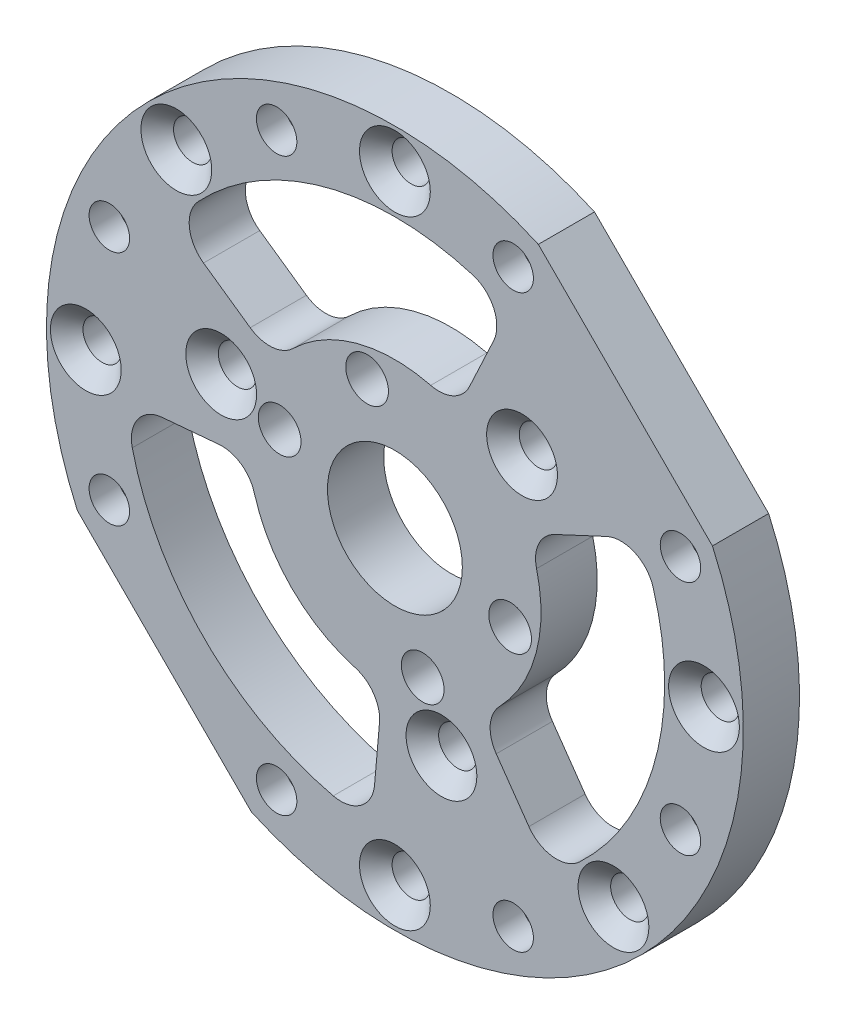
from build123d import *

# Parameters (mm, degrees)
SKETCH_1_R                          = 31
EXTRUDE_1_DEPTH                     = 5
SKETCH_2_R                          = 6
CUT_EXTRUDE_1_DEPTH                 = 6
HOLE_WIZARD_M3_1_D                  = 3.4
HOLE_WIZARD_M3_1_CSINK_D            = 6.3
HOLE_WIZARD_M3_1_CSINK_ANGLE        = 90
PATTERN_CIRCULAR_1_COUNT            = 8
CUT_EXTRUDE_2_DEPTH                 = 6
HOLE_WIZARD_M3_4_D                  = 3.4
HOLE_WIZARD_M3_4_CSINK_D            = 6.3
HOLE_WIZARD_M3_4_CSINK_ANGLE        = 90
PATTERN_CIRCULAR_3_COUNT            = 3
CUT_EXTRUDE_5_DEPTH                 = 2.5
HOLE_WIZARD_M3_2_D                  = 3.6
SKETCH_17_R                         = 0.3
CUT_EXTRUDE_6_DEPTH                 = 2.5
PATTERN_CIRCULAR_6_COUNT            = 6
PATTERN_CIRCULAR_7_COUNT            = 8
PATTERN_CIRCULAR_7_COPY_1_SKETCH_R  = 0.3
PATTERN_CIRCULAR_7_COPY_1_DEPTH     = 2.5
PATTERN_CIRCULAR_7_COPY_2_SKETCH_R  = 0.3
PATTERN_CIRCULAR_7_COPY_2_DEPTH     = 2.5
PATTERN_CIRCULAR_7_COPY_3_SKETCH_R  = 0.3
PATTERN_CIRCULAR_7_COPY_3_DEPTH     = 2.5
PATTERN_CIRCULAR_7_COPY_4_SKETCH_R  = 0.3
PATTERN_CIRCULAR_7_COPY_4_DEPTH     = 2.5
PATTERN_CIRCULAR_7_COPY_5_SKETCH_R  = 0.3
PATTERN_CIRCULAR_7_COPY_5_DEPTH     = 2.5
PATTERN_CIRCULAR_7_COPY_6_SKETCH_R  = 0.3
PATTERN_CIRCULAR_7_COPY_6_DEPTH     = 2.5
PATTERN_CIRCULAR_7_COPY_7_SKETCH_R  = 0.3
PATTERN_CIRCULAR_7_COPY_7_DEPTH     = 2.5
PATTERN_CIRCULAR_7_COPY_8_SKETCH_R  = 0.3
PATTERN_CIRCULAR_7_COPY_8_DEPTH     = 2.5
PATTERN_CIRCULAR_7_COPY_9_SKETCH_R  = 0.3
PATTERN_CIRCULAR_7_COPY_9_DEPTH     = 2.5
PATTERN_CIRCULAR_7_COPY_10_SKETCH_R = 0.3
PATTERN_CIRCULAR_7_COPY_10_DEPTH    = 2.5
PATTERN_CIRCULAR_7_COPY_11_SKETCH_R = 0.3
PATTERN_CIRCULAR_7_COPY_11_DEPTH    = 2.5
PATTERN_CIRCULAR_7_COPY_12_SKETCH_R = 0.3
PATTERN_CIRCULAR_7_COPY_12_DEPTH    = 2.5
PATTERN_CIRCULAR_7_COPY_13_SKETCH_R = 0.3
PATTERN_CIRCULAR_7_COPY_13_DEPTH    = 2.5
PATTERN_CIRCULAR_7_COPY_14_SKETCH_R = 0.3
PATTERN_CIRCULAR_7_COPY_14_DEPTH    = 2.5
PATTERN_CIRCULAR_7_COPY_15_SKETCH_R = 0.3
PATTERN_CIRCULAR_7_COPY_15_DEPTH    = 2.5
PATTERN_CIRCULAR_7_COPY_16_SKETCH_R = 0.3
PATTERN_CIRCULAR_7_COPY_16_DEPTH    = 2.5
PATTERN_CIRCULAR_7_COPY_17_SKETCH_R = 0.3
PATTERN_CIRCULAR_7_COPY_17_DEPTH    = 2.5
PATTERN_CIRCULAR_7_COPY_18_SKETCH_R = 0.3
PATTERN_CIRCULAR_7_COPY_18_DEPTH    = 2.5
PATTERN_CIRCULAR_7_COPY_19_SKETCH_R = 0.3
PATTERN_CIRCULAR_7_COPY_19_DEPTH    = 2.5
PATTERN_CIRCULAR_7_COPY_20_SKETCH_R = 0.3
PATTERN_CIRCULAR_7_COPY_20_DEPTH    = 2.5
PATTERN_CIRCULAR_7_COPY_21_SKETCH_R = 0.3
PATTERN_CIRCULAR_7_COPY_21_DEPTH    = 2.5
PATTERN_CIRCULAR_7_COPY_22_SKETCH_R = 0.3
PATTERN_CIRCULAR_7_COPY_22_DEPTH    = 2.5
PATTERN_CIRCULAR_7_COPY_23_SKETCH_R = 0.3
PATTERN_CIRCULAR_7_COPY_23_DEPTH    = 2.5
PATTERN_CIRCULAR_7_COPY_24_SKETCH_R = 0.3
PATTERN_CIRCULAR_7_COPY_24_DEPTH    = 2.5
PATTERN_CIRCULAR_7_COPY_25_SKETCH_R = 0.3
PATTERN_CIRCULAR_7_COPY_25_DEPTH    = 2.5
PATTERN_CIRCULAR_7_COPY_26_SKETCH_R = 0.3
PATTERN_CIRCULAR_7_COPY_26_DEPTH    = 2.5
PATTERN_CIRCULAR_7_COPY_27_SKETCH_R = 0.3
PATTERN_CIRCULAR_7_COPY_27_DEPTH    = 2.5
PATTERN_CIRCULAR_7_COPY_28_SKETCH_R = 0.3
PATTERN_CIRCULAR_7_COPY_28_DEPTH    = 2.5
PATTERN_CIRCULAR_7_COPY_29_SKETCH_R = 0.3
PATTERN_CIRCULAR_7_COPY_29_DEPTH    = 2.5
PATTERN_CIRCULAR_7_COPY_30_SKETCH_R = 0.3
PATTERN_CIRCULAR_7_COPY_30_DEPTH    = 2.5
PATTERN_CIRCULAR_7_COPY_31_SKETCH_R = 0.3
PATTERN_CIRCULAR_7_COPY_31_DEPTH    = 2.5
PATTERN_CIRCULAR_7_COPY_32_SKETCH_R = 0.3
PATTERN_CIRCULAR_7_COPY_32_DEPTH    = 2.5
PATTERN_CIRCULAR_7_COPY_33_SKETCH_R = 0.3
PATTERN_CIRCULAR_7_COPY_33_DEPTH    = 2.5
PATTERN_CIRCULAR_7_COPY_34_SKETCH_R = 0.3
PATTERN_CIRCULAR_7_COPY_34_DEPTH    = 2.5
PATTERN_CIRCULAR_7_COPY_35_SKETCH_R = 0.3
PATTERN_CIRCULAR_7_COPY_35_DEPTH    = 2.5
CUT_EXTRUDE_9_DEPTH                 = 6
FILLET_2_R                          = 3
PATTERN_CIRCULAR_10_COUNT           = 3
FILLET_2_OF_PATTERN_CIRCULAR_10_R   = 3
SKETCH_26_R                         = 1.9
CUT_EXTRUDE_10_DEPTH                = 3.5


with BuildPart() as part:
    # ｽｹｯﾁ1 → ﾎﾞｽ - 押し出し1 (new body)
    with BuildSketch(Plane.XY):
        Circle(SKETCH_1_R)
    extrude(amount=EXTRUDE_1_DEPTH)

    # ｽｹｯﾁ2 → ｶｯﾄ - 押し出し1 (cut, through all)
    with BuildSketch(Plane.XY.offset(5)):
        Circle(SKETCH_2_R)
    extrude(amount=-CUT_EXTRUDE_1_DEPTH, mode=Mode.SUBTRACT)

    # M3 平皿頭ねじ用皿穴1 (through all)
    with Locations(Plane.XY.offset(5)):
        with Locations((0, 27.5)):
            hole_wizard_m3_1 = CounterSinkHole(HOLE_WIZARD_M3_1_D / 2, HOLE_WIZARD_M3_1_CSINK_D / 2, counter_sink_angle=HOLE_WIZARD_M3_1_CSINK_ANGLE)

    # 円形ﾊﾟﾀｰﾝ1: M3 平皿頭ねじ用皿穴1 ×8 about axis, 2 skipped
    pattern_circular_1_axis = Axis((0, 0, 0), (0, 0, 1))
    add([hole_wizard_m3_1.rotate(pattern_circular_1_axis, i * 360 / PATTERN_CIRCULAR_1_COUNT) for i in range(1, PATTERN_CIRCULAR_1_COUNT) if i not in (3, 7)], mode=Mode.SUBTRACT)

    # ｽｹｯﾁ6 → ｶｯﾄ - 押し出し2 (cut, through all)
    with BuildSketch(Plane.XY.offset(5)):
        with BuildLine():
            Line((-12.760129962, -28.252063347), (-28.252063347, -12.760129962))
            ThreePointArc((-28.252063347, -12.760129962), (-21.920310217, -21.920310217), (-12.760129962, -28.252063347))
        make_face()
        with BuildLine():
            ThreePointArc((28.252063347, 12.760129962), (21.920310217, 21.920310217), (12.760129962, 28.252063347))
            Line((12.760129962, 28.252063347), (28.252063347, 12.760129962))
        make_face()
    extrude(amount=-CUT_EXTRUDE_2_DEPTH, mode=Mode.SUBTRACT)

    # M3 平皿頭ねじ用皿穴4 (through all)
    with Locations(Plane.XY.offset(5)):
        with Locations((11.313708499, 11.313708499)):
            hole_wizard_m3_4 = CounterSinkHole(HOLE_WIZARD_M3_4_D / 2, HOLE_WIZARD_M3_4_CSINK_D / 2, counter_sink_angle=HOLE_WIZARD_M3_4_CSINK_ANGLE)

    # 円形ﾊﾟﾀｰﾝ3: M3 平皿頭ねじ用皿穴4 ×3 about axis
    pattern_circular_3_axis = Axis((0, 0, 0), (0, 0, 1))
    for i in range(1, PATTERN_CIRCULAR_3_COUNT):
        add(hole_wizard_m3_4.rotate(pattern_circular_3_axis, i * 360 / PATTERN_CIRCULAR_3_COUNT), mode=Mode.SUBTRACT)

    # ｽｹｯﾁ16 → ｶｯﾄ - 押し出し5 (cut)
    with BuildSketch(Plane(origin=(0, 0, 0), x_dir=(-1, 0, 0), z_dir=(0, 0, -1))):
        Polygon((10.942038684, 22.229806329), (13.484176027, 24.18045692), (13.065931733, 27.357337735), (10.105550096, 28.583567959), (7.563412753, 26.632917368), (7.981657047, 23.456036553), align=None)
    cut_extrude_5 = extrude(amount=-CUT_EXTRUDE_5_DEPTH, mode=Mode.SUBTRACT)

    # Hole Wizard M3 _2 (through all)
    with Locations(Plane(origin=(0, 0, 2.5), x_dir=(-1, 0, 0), z_dir=(0, 0, -1))):
        with Locations((10.52379439, 25.406687144)):
            hole_wizard_m3_2 = Hole(HOLE_WIZARD_M3_2_D / 2)

    # ｽｹｯﾁ17 → ｶｯﾄ - 押し出し6 (cut)
    with BuildSketch(Plane(origin=(0, 0, 0), x_dir=(-1, 0, 0), z_dir=(0, 0, -1))):
        with Locations((10.105550096, 28.583567959)):
            Circle(SKETCH_17_R)
    cut_extrude_6 = extrude(amount=-CUT_EXTRUDE_6_DEPTH, mode=Mode.SUBTRACT)

    # 円形ﾊﾟﾀｰﾝ6: ｶｯﾄ - 押し出し6 ×6 about axis
    pattern_circular_6_axis = Axis((-10.52379439, 25.406687144, 0), (0, 0, 1))
    for i in range(1, PATTERN_CIRCULAR_6_COUNT):
        add(cut_extrude_6.rotate(pattern_circular_6_axis, i * 360 / PATTERN_CIRCULAR_6_COUNT), mode=Mode.SUBTRACT)

    # 円形ﾊﾟﾀｰﾝ7: ｶｯﾄ - 押し出し5, Hole Wizard M3 _2, ｶｯﾄ - 押し出し6 ×8 about axis
    pattern_circular_7_axis = Axis((0, 0, 0), (0, 0, 1))
    for i in range(1, PATTERN_CIRCULAR_7_COUNT):
        add(cut_extrude_5.rotate(pattern_circular_7_axis, i * 360 / PATTERN_CIRCULAR_7_COUNT), mode=Mode.SUBTRACT)
        add(hole_wizard_m3_2.rotate(pattern_circular_7_axis, i * 360 / PATTERN_CIRCULAR_7_COUNT), mode=Mode.SUBTRACT)
        add(cut_extrude_6.rotate(pattern_circular_7_axis, i * 360 / PATTERN_CIRCULAR_7_COUNT), mode=Mode.SUBTRACT)

    # 円形ﾊﾟﾀｰﾝ7 copy 1 sketch → 円形ﾊﾟﾀｰﾝ7 copy 1 (cut)
    with BuildSketch(Plane(origin=(-3.589470286, 27.264733688, 0), x_dir=(0.258819045, -0.965925826, 0), z_dir=(0, 0, -1))):
        with Locations((10.105550096, 28.583567959)):
            Circle(PATTERN_CIRCULAR_7_COPY_1_SKETCH_R)
    extrude(amount=-PATTERN_CIRCULAR_7_COPY_1_DEPTH, mode=Mode.SUBTRACT)

    # 円形ﾊﾟﾀｰﾝ7 copy 2 sketch → 円形ﾊﾟﾀｰﾝ7 copy 2 (cut)
    with BuildSketch(Plane(origin=(-21.817216858, 16.740939298, 0), x_dir=(0.866025404, -0.5, 0), z_dir=(0, 0, -1))):
        with Locations((10.105550096, 28.583567959)):
            Circle(PATTERN_CIRCULAR_7_COPY_2_SKETCH_R)
    extrude(amount=-PATTERN_CIRCULAR_7_COPY_2_DEPTH, mode=Mode.SUBTRACT)

    # 円形ﾊﾟﾀｰﾝ7 copy 3 sketch → 円形ﾊﾟﾀｰﾝ7 copy 3 (cut)
    with BuildSketch(Plane(origin=(-27.264733688, -3.589470286, 0), x_dir=(0.965925826, 0.258819045, 0), z_dir=(0, 0, -1))):
        with Locations((10.105550096, 28.583567959)):
            Circle(PATTERN_CIRCULAR_7_COPY_3_SKETCH_R)
    extrude(amount=-PATTERN_CIRCULAR_7_COPY_3_DEPTH, mode=Mode.SUBTRACT)

    # 円形ﾊﾟﾀｰﾝ7 copy 4 sketch → 円形ﾊﾟﾀｰﾝ7 copy 4 (cut)
    with BuildSketch(Plane(origin=(-16.740939298, -21.817216858, 0), x_dir=(0.5, 0.866025404, 0), z_dir=(0, 0, -1))):
        with Locations((10.105550096, 28.583567959)):
            Circle(PATTERN_CIRCULAR_7_COPY_4_SKETCH_R)
    extrude(amount=-PATTERN_CIRCULAR_7_COPY_4_DEPTH, mode=Mode.SUBTRACT)

    # 円形ﾊﾟﾀｰﾝ7 copy 5 sketch → 円形ﾊﾟﾀｰﾝ7 copy 5 (cut)
    with BuildSketch(Plane(origin=(3.589470286, -27.264733688, 0), x_dir=(-0.258819045, 0.965925826, 0), z_dir=(0, 0, -1))):
        with Locations((10.105550096, 28.583567959)):
            Circle(PATTERN_CIRCULAR_7_COPY_5_SKETCH_R)
    extrude(amount=-PATTERN_CIRCULAR_7_COPY_5_DEPTH, mode=Mode.SUBTRACT)

    # 円形ﾊﾟﾀｰﾝ7 copy 6 sketch → 円形ﾊﾟﾀｰﾝ7 copy 6 (cut)
    with BuildSketch(Plane(origin=(21.817216858, -16.740939298, 0), x_dir=(-0.866025404, 0.5, 0), z_dir=(0, 0, -1))):
        with Locations((10.105550096, 28.583567959)):
            Circle(PATTERN_CIRCULAR_7_COPY_6_SKETCH_R)
    extrude(amount=-PATTERN_CIRCULAR_7_COPY_6_DEPTH, mode=Mode.SUBTRACT)

    # 円形ﾊﾟﾀｰﾝ7 copy 7 sketch → 円形ﾊﾟﾀｰﾝ7 copy 7 (cut)
    with BuildSketch(Plane(origin=(27.264733688, 3.589470286, 0), x_dir=(-0.965925826, -0.258819045, 0), z_dir=(0, 0, -1))):
        with Locations((10.105550096, 28.583567959)):
            Circle(PATTERN_CIRCULAR_7_COPY_7_SKETCH_R)
    extrude(amount=-PATTERN_CIRCULAR_7_COPY_7_DEPTH, mode=Mode.SUBTRACT)

    # 円形ﾊﾟﾀｰﾝ7 copy 8 sketch → 円形ﾊﾟﾀｰﾝ7 copy 8 (cut)
    with BuildSketch(Plane(origin=(-28.99615743, 37.788528078, 0), x_dir=(0.965925826, -0.258819045, 0), z_dir=(0, 0, -1))):
        with Locations((10.105550096, 28.583567959)):
            Circle(PATTERN_CIRCULAR_7_COPY_8_SKETCH_R)
    extrude(amount=-PATTERN_CIRCULAR_7_COPY_8_DEPTH, mode=Mode.SUBTRACT)

    # 円形ﾊﾟﾀｰﾝ7 copy 9 sketch → 円形ﾊﾟﾀｰﾝ7 copy 9 (cut)
    with BuildSketch(Plane(origin=(-47.223904002, 6.217144908, 0), x_dir=(0.866025404, 0.5, 0), z_dir=(0, 0, -1))):
        with Locations((10.105550096, 28.583567959)):
            Circle(PATTERN_CIRCULAR_7_COPY_9_SKETCH_R)
    extrude(amount=-PATTERN_CIRCULAR_7_COPY_9_DEPTH, mode=Mode.SUBTRACT)

    # 円形ﾊﾟﾀｰﾝ7 copy 10 sketch → 円形ﾊﾟﾀｰﾝ7 copy 10 (cut)
    with BuildSketch(Plane(origin=(-37.788528078, -28.99615743, 0), x_dir=(0.258819045, 0.965925826, 0), z_dir=(0, 0, -1))):
        with Locations((10.105550096, 28.583567959)):
            Circle(PATTERN_CIRCULAR_7_COPY_10_SKETCH_R)
    extrude(amount=-PATTERN_CIRCULAR_7_COPY_10_DEPTH, mode=Mode.SUBTRACT)

    # 円形ﾊﾟﾀｰﾝ7 copy 11 sketch → 円形ﾊﾟﾀｰﾝ7 copy 11 (cut)
    with BuildSketch(Plane(origin=(-6.217144908, -47.223904002, 0), x_dir=(-0.5, 0.866025404, 0), z_dir=(0, 0, -1))):
        with Locations((10.105550096, 28.583567959)):
            Circle(PATTERN_CIRCULAR_7_COPY_11_SKETCH_R)
    extrude(amount=-PATTERN_CIRCULAR_7_COPY_11_DEPTH, mode=Mode.SUBTRACT)

    # 円形ﾊﾟﾀｰﾝ7 copy 12 sketch → 円形ﾊﾟﾀｰﾝ7 copy 12 (cut)
    with BuildSketch(Plane(origin=(28.99615743, -37.788528078, 0), x_dir=(-0.965925826, 0.258819045, 0), z_dir=(0, 0, -1))):
        with Locations((10.105550096, 28.583567959)):
            Circle(PATTERN_CIRCULAR_7_COPY_12_SKETCH_R)
    extrude(amount=-PATTERN_CIRCULAR_7_COPY_12_DEPTH, mode=Mode.SUBTRACT)

    # 円形ﾊﾟﾀｰﾝ7 copy 13 sketch → 円形ﾊﾟﾀｰﾝ7 copy 13 (cut)
    with BuildSketch(Plane(origin=(47.223904002, -6.217144908, 0), x_dir=(-0.866025404, -0.5, 0), z_dir=(0, 0, -1))):
        with Locations((10.105550096, 28.583567959)):
            Circle(PATTERN_CIRCULAR_7_COPY_13_SKETCH_R)
    extrude(amount=-PATTERN_CIRCULAR_7_COPY_13_DEPTH, mode=Mode.SUBTRACT)

    # 円形ﾊﾟﾀｰﾝ7 copy 14 sketch → 円形ﾊﾟﾀｰﾝ7 copy 14 (cut)
    with BuildSketch(Plane(origin=(37.788528078, 28.99615743, 0), x_dir=(-0.258819045, -0.965925826, 0), z_dir=(0, 0, -1))):
        with Locations((10.105550096, 28.583567959)):
            Circle(PATTERN_CIRCULAR_7_COPY_14_SKETCH_R)
    extrude(amount=-PATTERN_CIRCULAR_7_COPY_14_DEPTH, mode=Mode.SUBTRACT)

    # 円形ﾊﾟﾀｰﾝ7 copy 15 sketch → 円形ﾊﾟﾀｰﾝ7 copy 15 (cut)
    with BuildSketch(Plane(origin=(-50.813374288, 21.04758878, 0), x_dir=(0.707106781, 0.707106781, 0), z_dir=(0, 0, -1))):
        with Locations((10.105550096, 28.583567959)):
            Circle(PATTERN_CIRCULAR_7_COPY_15_SKETCH_R)
    extrude(amount=-PATTERN_CIRCULAR_7_COPY_15_DEPTH, mode=Mode.SUBTRACT)

    # 円形ﾊﾟﾀｰﾝ7 copy 16 sketch → 円形ﾊﾟﾀｰﾝ7 copy 16 (cut)
    with BuildSketch(Plane(origin=(-50.813374288, -21.04758878, 0), x_dir=(0, 1, 0), z_dir=(0, 0, -1))):
        with Locations((10.105550096, 28.583567959)):
            Circle(PATTERN_CIRCULAR_7_COPY_16_SKETCH_R)
    extrude(amount=-PATTERN_CIRCULAR_7_COPY_16_DEPTH, mode=Mode.SUBTRACT)

    # 円形ﾊﾟﾀｰﾝ7 copy 17 sketch → 円形ﾊﾟﾀｰﾝ7 copy 17 (cut)
    with BuildSketch(Plane(origin=(-21.04758878, -50.813374288, 0), x_dir=(-0.707106781, 0.707106781, 0), z_dir=(0, 0, -1))):
        with Locations((10.105550096, 28.583567959)):
            Circle(PATTERN_CIRCULAR_7_COPY_17_SKETCH_R)
    extrude(amount=-PATTERN_CIRCULAR_7_COPY_17_DEPTH, mode=Mode.SUBTRACT)

    # 円形ﾊﾟﾀｰﾝ7 copy 18 sketch → 円形ﾊﾟﾀｰﾝ7 copy 18 (cut)
    with BuildSketch(Plane(origin=(21.04758878, -50.813374288, 0), x_dir=(-1, 0, 0), z_dir=(0, 0, -1))):
        with Locations((10.105550096, 28.583567959)):
            Circle(PATTERN_CIRCULAR_7_COPY_18_SKETCH_R)
    extrude(amount=-PATTERN_CIRCULAR_7_COPY_18_DEPTH, mode=Mode.SUBTRACT)

    # 円形ﾊﾟﾀｰﾝ7 copy 19 sketch → 円形ﾊﾟﾀｰﾝ7 copy 19 (cut)
    with BuildSketch(Plane(origin=(50.813374288, -21.04758878, 0), x_dir=(-0.707106781, -0.707106781, 0), z_dir=(0, 0, -1))):
        with Locations((10.105550096, 28.583567959)):
            Circle(PATTERN_CIRCULAR_7_COPY_19_SKETCH_R)
    extrude(amount=-PATTERN_CIRCULAR_7_COPY_19_DEPTH, mode=Mode.SUBTRACT)

    # 円形ﾊﾟﾀｰﾝ7 copy 20 sketch → 円形ﾊﾟﾀｰﾝ7 copy 20 (cut)
    with BuildSketch(Plane(origin=(50.813374288, 21.04758878, 0), x_dir=(0, -1, 0), z_dir=(0, 0, -1))):
        with Locations((10.105550096, 28.583567959)):
            Circle(PATTERN_CIRCULAR_7_COPY_20_SKETCH_R)
    extrude(amount=-PATTERN_CIRCULAR_7_COPY_20_DEPTH, mode=Mode.SUBTRACT)

    # 円形ﾊﾟﾀｰﾝ7 copy 21 sketch → 円形ﾊﾟﾀｰﾝ7 copy 21 (cut)
    with BuildSketch(Plane(origin=(21.04758878, 50.813374288, 0), x_dir=(0.707106781, -0.707106781, 0), z_dir=(0, 0, -1))):
        with Locations((10.105550096, 28.583567959)):
            Circle(PATTERN_CIRCULAR_7_COPY_21_SKETCH_R)
    extrude(amount=-PATTERN_CIRCULAR_7_COPY_21_DEPTH, mode=Mode.SUBTRACT)

    # 円形ﾊﾟﾀｰﾝ7 copy 22 sketch → 円形ﾊﾟﾀｰﾝ7 copy 22 (cut)
    with BuildSketch(Plane(origin=(-47.223904002, -6.217144908, 0), x_dir=(-0.258819045, 0.965925826, 0), z_dir=(0, 0, -1))):
        with Locations((10.105550096, 28.583567959)):
            Circle(PATTERN_CIRCULAR_7_COPY_22_SKETCH_R)
    extrude(amount=-PATTERN_CIRCULAR_7_COPY_22_DEPTH, mode=Mode.SUBTRACT)

    # 円形ﾊﾟﾀｰﾝ7 copy 23 sketch → 円形ﾊﾟﾀｰﾝ7 copy 23 (cut)
    with BuildSketch(Plane(origin=(-28.99615743, -37.788528078, 0), x_dir=(-0.866025404, 0.5, 0), z_dir=(0, 0, -1))):
        with Locations((10.105550096, 28.583567959)):
            Circle(PATTERN_CIRCULAR_7_COPY_23_SKETCH_R)
    extrude(amount=-PATTERN_CIRCULAR_7_COPY_23_DEPTH, mode=Mode.SUBTRACT)

    # 円形ﾊﾟﾀｰﾝ7 copy 24 sketch → 円形ﾊﾟﾀｰﾝ7 copy 24 (cut)
    with BuildSketch(Plane(origin=(6.217144908, -47.223904002, 0), x_dir=(-0.965925826, -0.258819045, 0), z_dir=(0, 0, -1))):
        with Locations((10.105550096, 28.583567959)):
            Circle(PATTERN_CIRCULAR_7_COPY_24_SKETCH_R)
    extrude(amount=-PATTERN_CIRCULAR_7_COPY_24_DEPTH, mode=Mode.SUBTRACT)

    # 円形ﾊﾟﾀｰﾝ7 copy 25 sketch → 円形ﾊﾟﾀｰﾝ7 copy 25 (cut)
    with BuildSketch(Plane(origin=(37.788528078, -28.99615743, 0), x_dir=(-0.5, -0.866025404, 0), z_dir=(0, 0, -1))):
        with Locations((10.105550096, 28.583567959)):
            Circle(PATTERN_CIRCULAR_7_COPY_25_SKETCH_R)
    extrude(amount=-PATTERN_CIRCULAR_7_COPY_25_DEPTH, mode=Mode.SUBTRACT)

    # 円形ﾊﾟﾀｰﾝ7 copy 26 sketch → 円形ﾊﾟﾀｰﾝ7 copy 26 (cut)
    with BuildSketch(Plane(origin=(47.223904002, 6.217144908, 0), x_dir=(0.258819045, -0.965925826, 0), z_dir=(0, 0, -1))):
        with Locations((10.105550096, 28.583567959)):
            Circle(PATTERN_CIRCULAR_7_COPY_26_SKETCH_R)
    extrude(amount=-PATTERN_CIRCULAR_7_COPY_26_DEPTH, mode=Mode.SUBTRACT)

    # 円形ﾊﾟﾀｰﾝ7 copy 27 sketch → 円形ﾊﾟﾀｰﾝ7 copy 27 (cut)
    with BuildSketch(Plane(origin=(28.99615743, 37.788528078, 0), x_dir=(0.866025404, -0.5, 0), z_dir=(0, 0, -1))):
        with Locations((10.105550096, 28.583567959)):
            Circle(PATTERN_CIRCULAR_7_COPY_27_SKETCH_R)
    extrude(amount=-PATTERN_CIRCULAR_7_COPY_27_DEPTH, mode=Mode.SUBTRACT)

    # 円形ﾊﾟﾀｰﾝ7 copy 28 sketch → 円形ﾊﾟﾀｰﾝ7 copy 28 (cut)
    with BuildSketch(Plane(origin=(-6.217144908, 47.223904002, 0), x_dir=(0.965925826, 0.258819045, 0), z_dir=(0, 0, -1))):
        with Locations((10.105550096, 28.583567959)):
            Circle(PATTERN_CIRCULAR_7_COPY_28_SKETCH_R)
    extrude(amount=-PATTERN_CIRCULAR_7_COPY_28_DEPTH, mode=Mode.SUBTRACT)

    # 円形ﾊﾟﾀｰﾝ7 copy 29 sketch → 円形ﾊﾟﾀｰﾝ7 copy 29 (cut)
    with BuildSketch(Plane(origin=(-21.817216858, -16.740939298, 0), x_dir=(-0.965925826, 0.258819045, 0), z_dir=(0, 0, -1))):
        with Locations((10.105550096, 28.583567959)):
            Circle(PATTERN_CIRCULAR_7_COPY_29_SKETCH_R)
    extrude(amount=-PATTERN_CIRCULAR_7_COPY_29_DEPTH, mode=Mode.SUBTRACT)

    # 円形ﾊﾟﾀｰﾝ7 copy 30 sketch → 円形ﾊﾟﾀｰﾝ7 copy 30 (cut)
    with BuildSketch(Plane(origin=(-3.589470286, -27.264733688, 0), x_dir=(-0.866025404, -0.5, 0), z_dir=(0, 0, -1))):
        with Locations((10.105550096, 28.583567959)):
            Circle(PATTERN_CIRCULAR_7_COPY_30_SKETCH_R)
    extrude(amount=-PATTERN_CIRCULAR_7_COPY_30_DEPTH, mode=Mode.SUBTRACT)

    # 円形ﾊﾟﾀｰﾝ7 copy 31 sketch → 円形ﾊﾟﾀｰﾝ7 copy 31 (cut)
    with BuildSketch(Plane(origin=(16.740939298, -21.817216858, 0), x_dir=(-0.258819045, -0.965925826, 0), z_dir=(0, 0, -1))):
        with Locations((10.105550096, 28.583567959)):
            Circle(PATTERN_CIRCULAR_7_COPY_31_SKETCH_R)
    extrude(amount=-PATTERN_CIRCULAR_7_COPY_31_DEPTH, mode=Mode.SUBTRACT)

    # 円形ﾊﾟﾀｰﾝ7 copy 32 sketch → 円形ﾊﾟﾀｰﾝ7 copy 32 (cut)
    with BuildSketch(Plane(origin=(27.264733688, -3.589470286, 0), x_dir=(0.5, -0.866025404, 0), z_dir=(0, 0, -1))):
        with Locations((10.105550096, 28.583567959)):
            Circle(PATTERN_CIRCULAR_7_COPY_32_SKETCH_R)
    extrude(amount=-PATTERN_CIRCULAR_7_COPY_32_DEPTH, mode=Mode.SUBTRACT)

    # 円形ﾊﾟﾀｰﾝ7 copy 33 sketch → 円形ﾊﾟﾀｰﾝ7 copy 33 (cut)
    with BuildSketch(Plane(origin=(21.817216858, 16.740939298, 0), x_dir=(0.965925826, -0.258819045, 0), z_dir=(0, 0, -1))):
        with Locations((10.105550096, 28.583567959)):
            Circle(PATTERN_CIRCULAR_7_COPY_33_SKETCH_R)
    extrude(amount=-PATTERN_CIRCULAR_7_COPY_33_DEPTH, mode=Mode.SUBTRACT)

    # 円形ﾊﾟﾀｰﾝ7 copy 34 sketch → 円形ﾊﾟﾀｰﾝ7 copy 34 (cut)
    with BuildSketch(Plane(origin=(3.589470286, 27.264733688, 0), x_dir=(0.866025404, 0.5, 0), z_dir=(0, 0, -1))):
        with Locations((10.105550096, 28.583567959)):
            Circle(PATTERN_CIRCULAR_7_COPY_34_SKETCH_R)
    extrude(amount=-PATTERN_CIRCULAR_7_COPY_34_DEPTH, mode=Mode.SUBTRACT)

    # 円形ﾊﾟﾀｰﾝ7 copy 35 sketch → 円形ﾊﾟﾀｰﾝ7 copy 35 (cut)
    with BuildSketch(Plane(origin=(-16.740939298, 21.817216858, 0), x_dir=(0.258819045, 0.965925826, 0), z_dir=(0, 0, -1))):
        with Locations((10.105550096, 28.583567959)):
            Circle(PATTERN_CIRCULAR_7_COPY_35_SKETCH_R)
    extrude(amount=-PATTERN_CIRCULAR_7_COPY_35_DEPTH, mode=Mode.SUBTRACT)

    # ｽｹｯﾁ24 → ｶｯﾄ - 押し出し9 (cut, through all)
    with BuildSketch(Plane.XY.offset(5)):
        with BuildLine():
            Line((7.456493673, -10.648976576), (13.765834472, -19.659649063))
            ThreePointArc((13.765834472, -19.659649063), (23.182219831, -6.211657082), (21.751386889, 10.142838282))
            Line((21.751386889, 10.142838282), (11.782001231, 5.494037403))
            ThreePointArc((11.782001231, 5.494037403), (12.557035742, -3.364647586), (7.456493673, -10.648976576))
        make_face()
    cut_extrude_9 = extrude(amount=-CUT_EXTRUDE_9_DEPTH, mode=Mode.SUBTRACT)

    # ﾌｨﾚｯﾄ2
    fillet_2_edges = [part.edges().sort_by_distance(p)[0] for p in [
        (7.456493673, -10.648976576, 2.5),
        (11.782001231, 5.494037403, 2.5),
        (21.751386889, 10.142838282, 2.5),
        (13.765834472, -19.659649063, 2.5),
    ]]
    fillet(fillet_2_edges, radius=FILLET_2_R)

    # 円形ﾊﾟﾀｰﾝ10: ｶｯﾄ - 押し出し9 ×3 about axis
    pattern_circular_10_axis = Axis((0, 0, 0), (0, 0, 1))
    for i in range(1, PATTERN_CIRCULAR_10_COUNT):
        add(cut_extrude_9.rotate(pattern_circular_10_axis, i * 360 / PATTERN_CIRCULAR_10_COUNT), mode=Mode.SUBTRACT)

    # ﾌｨﾚｯﾄ2 of 円形ﾊﾟﾀｰﾝ10
    fillet_2_of_pattern_circular_10_edges = [part.edges().sort_by_distance(p)[0] for p in [
        (5.494037403, 11.782001231, 2.5),
        (-10.648976576, 7.456493673, 2.5),
        (-19.659649063, 13.765834472, 2.5),
        (10.142838282, 21.751386889, 2.5),
        (-12.950531075, -1.133024656, 2.5),
        (-1.133024656, -12.950531075, 2.5),
        (-2.091737826, -23.908672754, 2.5),
        (-23.908672754, -2.091737826, 2.5),
    ]]
    fillet(fillet_2_of_pattern_circular_10_edges, radius=FILLET_2_OF_PATTERN_CIRCULAR_10_R)

    # ｽｹｯﾁ26 → ｶｯﾄ - 押し出し10 (cut)
    with BuildSketch(Plane.XY.offset(5)):
        with Locations((-2.474873734, 10.253048327)):
            Circle(SKETCH_26_R)
        with Locations((10.253048327, -2.474873734)):
            Circle(SKETCH_26_R)
        with Locations((-10.253048327, 2.474873734)):
            Circle(SKETCH_26_R)
        with Locations((2.474873734, -10.253048327)):
            Circle(SKETCH_26_R)
    extrude(amount=-CUT_EXTRUDE_10_DEPTH, mode=Mode.SUBTRACT)


solid = part.part
